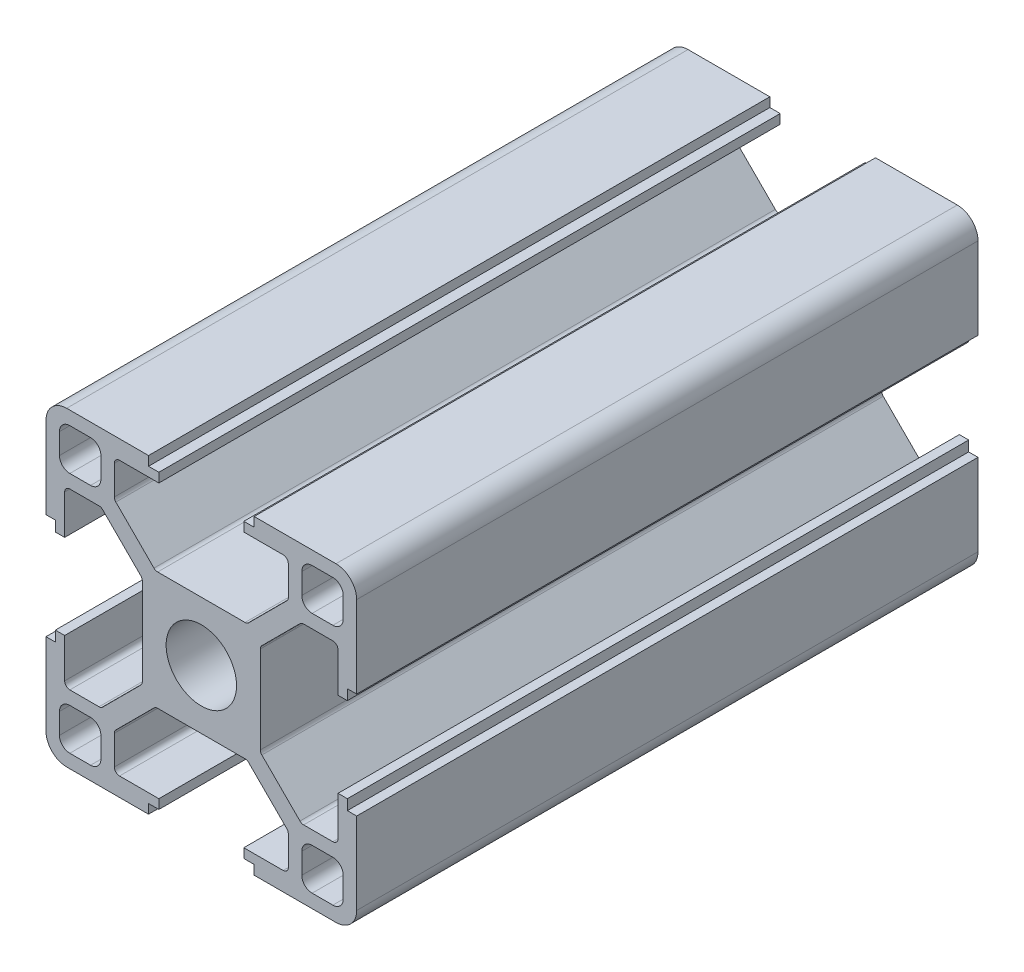
from build123d import *

# Parameters (mm, degrees)
SKETCH_1_W                       = 4
SKETCH_1_H                       = 4
EXTRUDE_1_DEPTH                  = 60
FILLET_1_R                       = 1
FILLET_2_R                       = 2
FILLET_3_R                       = 0.5
PATTERN_CIRCULAR_1_COUNT         = 4
FILLET_1_OF_PATTERN_CIRCULAR_1_R = 1
FILLET_2_OF_PATTERN_CIRCULAR_1_R = 2
FILLET_3_OF_PATTERN_CIRCULAR_1_R = 0.5
SKETCH_2_R                       = 3.4
CUT_EXTRUDE_1_DEPTH              = 61
SKETCH_3_R                       = 3.15
CUT_EXTRUDE_2_DEPTH              = 10
SKETCH_4_R                       = 4.1
CUT_EXTRUDE_3_DEPTH              = 21.7


with BuildPart() as part:
    # 草图1 → 凸台-拉伸1 (new body)
    with BuildSketch(Plane.XY):
        Polygon((5.7, 0), (5.7, 4.427207794), (9.672792206, 8.4), (13.2, 8.4), (13.2, 4.1), (14.1, 4.1), (14.1, 5.1), (15, 5.1), (15, 15), (5.1, 15), (5.1, 14.1), (4.1, 14.1), (4.1, 13.2), (8.4, 13.2), (8.4, 9.672792206), (4.427207794, 5.7), (0, 5.7), (0, 0), align=None)
        with Locations((11.7, 11.7)):
            Rectangle(SKETCH_1_W, SKETCH_1_H, mode=Mode.SUBTRACT)
    extrude_1 = extrude(amount=EXTRUDE_1_DEPTH)

    # 圆角1
    fillet_1_edges = [part.edges().sort_by_distance(p)[0] for p in [
        (13.7, 9.7, 30),
        (13.7, 13.7, 30),
        (9.7, 13.7, 30),
        (9.7, 9.7, 30),
    ]]
    fillet(fillet_1_edges, radius=FILLET_1_R)

    # 圆角2
    fillet_2_edges = [part.edges().sort_by_distance(p)[0] for p in [
        (15, 15, 30),
    ]]
    fillet(fillet_2_edges, radius=FILLET_2_R)

    # 圆角3
    fillet_3_edges = [part.edges().sort_by_distance(p)[0] for p in [
        (4.427207794, 5.7, 30),
        (8.4, 9.672792206, 30),
        (8.4, 13.2, 30),
        (13.2, 8.4, 30),
        (9.672792206, 8.4, 30),
        (5.7, 4.427207794, 30),
    ]]
    fillet(fillet_3_edges, radius=FILLET_3_R)

    # 阵列(圆周)1: 凸台-拉伸1 ×4 about axis
    pattern_circular_1_axis = Axis((0, 0, 0), (0, 0, 1))
    for i in range(1, PATTERN_CIRCULAR_1_COUNT):
        add(extrude_1.rotate(pattern_circular_1_axis, i * 360 / PATTERN_CIRCULAR_1_COUNT))

    # 圆角1 of 阵列(圆周)1
    fillet_1_of_pattern_circular_1_edges = [part.edges().sort_by_distance(p)[0] for p in [
        (-9.7, 13.7, 30),
        (-13.7, 13.7, 30),
        (-13.7, 9.7, 30),
        (-9.7, 9.7, 30),
        (-13.7, -9.7, 30),
        (-13.7, -13.7, 30),
        (-9.7, -13.7, 30),
        (-9.7, -9.7, 30),
        (9.7, -13.7, 30),
        (13.7, -13.7, 30),
        (13.7, -9.7, 30),
        (9.7, -9.7, 30),
    ]]
    fillet(fillet_1_of_pattern_circular_1_edges, radius=FILLET_1_OF_PATTERN_CIRCULAR_1_R)

    # 圆角2 of 阵列(圆周)1
    fillet_2_of_pattern_circular_1_edges = [part.edges().sort_by_distance(p)[0] for p in [
        (-15, 15, 30),
        (-15, -15, 30),
        (15, -15, 30),
    ]]
    fillet(fillet_2_of_pattern_circular_1_edges, radius=FILLET_2_OF_PATTERN_CIRCULAR_1_R)

    # 圆角3 of 阵列(圆周)1
    fillet_3_of_pattern_circular_1_edges = [part.edges().sort_by_distance(p)[0] for p in [
        (-5.7, 4.427207794, 30),
        (-9.672792206, 8.4, 30),
        (-13.2, 8.4, 30),
        (-8.4, 13.2, 30),
        (-8.4, 9.672792206, 30),
        (-4.427207794, 5.7, 30),
        (-4.427207794, -5.7, 30),
        (-8.4, -9.672792206, 30),
        (-8.4, -13.2, 30),
        (-13.2, -8.4, 30),
        (-9.672792206, -8.4, 30),
        (-5.7, -4.427207794, 30),
        (5.7, -4.427207794, 30),
        (9.672792206, -8.4, 30),
        (13.2, -8.4, 30),
        (8.4, -13.2, 30),
        (8.4, -9.672792206, 30),
        (4.427207794, -5.7, 30),
    ]]
    fillet(fillet_3_of_pattern_circular_1_edges, radius=FILLET_3_OF_PATTERN_CIRCULAR_1_R)

    # 草图2 → 切除-拉伸1 (cut, through all)
    with BuildSketch(Plane.XY.offset(60)):
        Circle(SKETCH_2_R)
    extrude(amount=-CUT_EXTRUDE_1_DEPTH, mode=Mode.SUBTRACT)

    # 草图3 → 切除-拉伸2 (cut, symmetric)
    with BuildSketch(Plane(origin=(0, 0, 0), x_dir=(0, 0, -1), z_dir=(1, 0, 0))):
        with Locations((-45, 0)):
            Circle(SKETCH_3_R)
        with Locations((-15, 0)):
            Circle(SKETCH_3_R)
    extrude(amount=CUT_EXTRUDE_2_DEPTH, both=True, mode=Mode.SUBTRACT)

    # 草图4 → 切除-拉伸3 (cut, through all)
    with BuildSketch(Plane(origin=(0, 5.7, 0), x_dir=(1, 0, 0), z_dir=(0, 1, 0))):
        with Locations((0, -30)):
            Circle(SKETCH_4_R)
    extrude(amount=-CUT_EXTRUDE_3_DEPTH, mode=Mode.SUBTRACT)


solid = part.part
